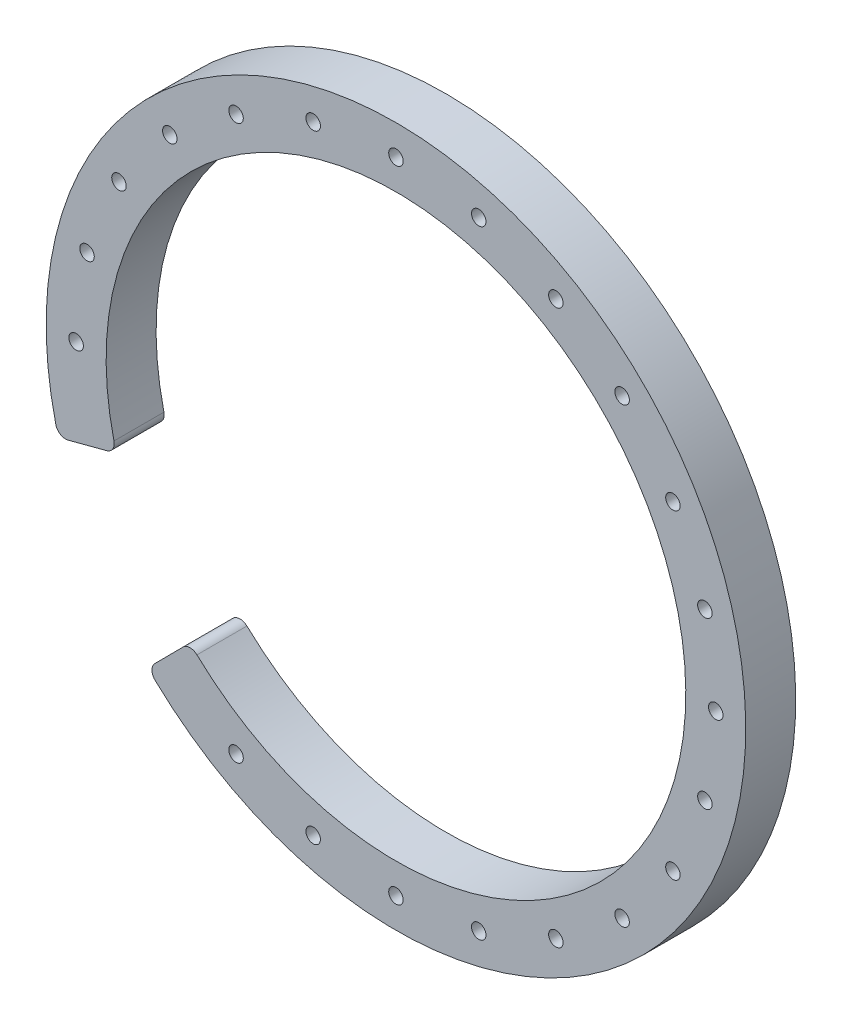
from build123d import *

# Parameters (mm, degrees)
SKETCH1_R           = 1.450000001
BOSS_EXTRUDE1_DEPTH = 10


with BuildPart() as part:
    # Sketch1 → Boss-Extrude1 (new body)
    with BuildSketch(Plane.XY):
        with BuildLine():
            Line((-13.21790593, 0.411052326), (-17.105565361, -0.61539898))
            Line((-17.105565361, -0.61539898), (-20.954961557, -1.631747717))
            ThreePointArc((-20.954961557, -1.631747717), (-22.49079308, -1.415225897), (-23.410010994, -0.165946667))
            ThreePointArc((-23.410010994, -0.165946667), (105.268891372, 51.211716755), (-3.564921525, -34.53864991))
            ThreePointArc((-3.564921525, -34.53864991), (-4.187220117, -33.11794423), (-3.606817752, -31.679614205))
            Line((-3.606817752, -31.679614205), (-0.801935828, -28.854113678))
            Line((-0.801935828, -28.854113678), (2.030826794, -26.000527503))
            ThreePointArc((2.030826794, -26.000527503), (3.417973795, -25.409812538), (4.823439838, -25.955510416))
            ThreePointArc((4.823439838, -25.955510416), (94.876586526, 45.211716755), (-11.782613467, 2.807017621))
            ThreePointArc((-11.782613467, 2.807017621), (-12.012758263, 1.316999385), (-13.21790593, 0.411052326))
        make_face()
        with Locations((-17.172139776, 32.776135645)):
            Circle(SKETCH1_R, mode=Mode.SUBTRACT)
        with Locations((-10.778512735, 48.211716758)):
            Circle(SKETCH1_R, mode=Mode.SUBTRACT)
        with Locations((-19.352886894, 16.211716758)):
            Circle(SKETCH1_R, mode=Mode.SUBTRACT)
        with Locations((106.466365989, -0.352702128)):
            Circle(SKETCH1_R, mode=Mode.SUBTRACT)
        with Locations((100.07273895, -15.788283242)):
            Circle(SKETCH1_R, mode=Mode.SUBTRACT)
        with Locations((89.901947104, -29.043117238)):
            Circle(SKETCH1_R, mode=Mode.SUBTRACT)
        with Locations((76.647113107, -39.213909086)):
            Circle(SKETCH1_R, mode=Mode.SUBTRACT)
        with Locations((61.211531993, -45.607536126)):
            Circle(SKETCH1_R, mode=Mode.SUBTRACT)
        with Locations((44.647113106, -47.788283244)):
            Circle(SKETCH1_R, mode=Mode.SUBTRACT)
        with Locations((28.082694219, -45.607536126)):
            Circle(SKETCH1_R, mode=Mode.SUBTRACT)
        with Locations((12.647113106, -39.213909086)):
            Circle(SKETCH1_R, mode=Mode.SUBTRACT)
        with Locations((-0.607720889, 61.466550753)):
            Circle(SKETCH1_R, mode=Mode.SUBTRACT)
        with Locations((12.647113108, 71.637342599)):
            Circle(SKETCH1_R, mode=Mode.SUBTRACT)
        with Locations((28.08269422, 78.030969639)):
            Circle(SKETCH1_R, mode=Mode.SUBTRACT)
        with Locations((44.647113106, 80.211716756)):
            Circle(SKETCH1_R, mode=Mode.SUBTRACT)
        with Locations((61.211531992, 78.030969639)):
            Circle(SKETCH1_R, mode=Mode.SUBTRACT)
        with Locations((76.647113105, 71.637342599)):
            Circle(SKETCH1_R, mode=Mode.SUBTRACT)
        with Locations((89.901947102, 61.466550752)):
            Circle(SKETCH1_R, mode=Mode.SUBTRACT)
        with Locations((100.072738948, 48.211716757)):
            Circle(SKETCH1_R, mode=Mode.SUBTRACT)
        with Locations((106.466365989, 32.776135644)):
            Circle(SKETCH1_R, mode=Mode.SUBTRACT)
        with Locations((108.647113106, 16.211716758)):
            Circle(SKETCH1_R, mode=Mode.SUBTRACT)
    extrude(amount=BOSS_EXTRUDE1_DEPTH)


solid = part.part
